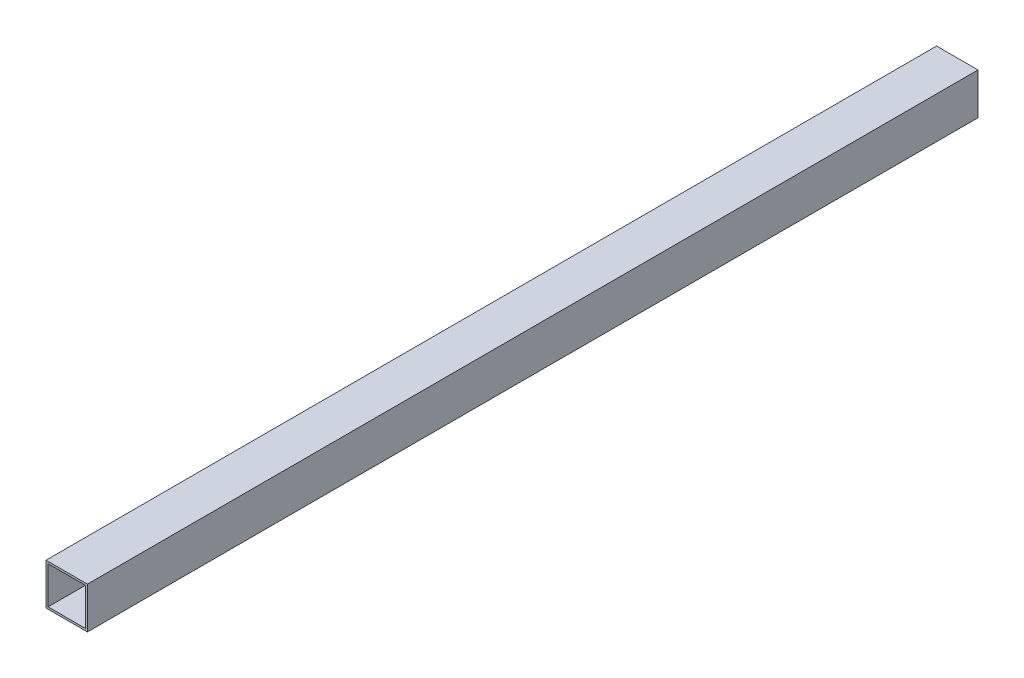
from build123d import *

# Parameters (mm, degrees)
SKETCH1_W           = 20
SKETCH1_H           = 20
SKETCH1_W_2         = 18
SKETCH1_H_2         = 18
BOSS_EXTRUDE1_DEPTH = 430


with BuildPart() as part:
    # Sketch1 → Boss-Extrude1 (new body)
    with BuildSketch(Plane.XY):
        with Locations((10, -10)):
            Rectangle(SKETCH1_W, SKETCH1_H)
        with Locations((10, -10)):
            Rectangle(SKETCH1_W_2, SKETCH1_H_2, mode=Mode.SUBTRACT)
    extrude(amount=BOSS_EXTRUDE1_DEPTH)


solid = part.part
